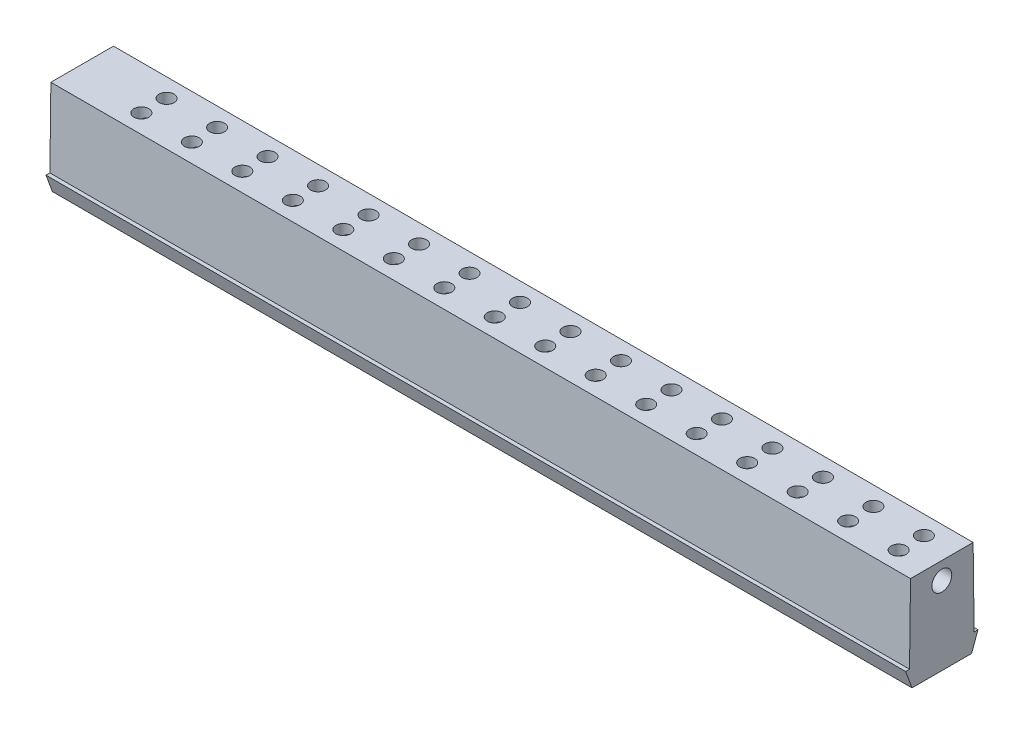
from build123d import *

# Parameters (mm, degrees)
BOSS_EXTRUDE1_DEPTH = 86.5
SKETCH2_R           = 1
CUT_EXTRUDE1_DEPTH  = 84
SKETCH3_R           = 0.9144
CUT_EXTRUDE2_DEPTH  = 5.207
SKETCH4_R           = 0.75
CUT_EXTRUDE3_DEPTH  = 5.08
LPATTERN1_COUNT     = 16
LPATTERN1_PITCH     = 5.08


with BuildPart() as part:
    # Sketch1 → Boss-Extrude1 (new body)
    with BuildSketch(Plane(origin=(0, 0, 0), x_dir=(0, 0, -1), z_dir=(1, 0, 0))):
        Polygon((-3, 0), (3, 0), (3.64, 1.75), (3.25, 1.75), (3.15, 9.6), (-3.15, 9.6), (-3.25, 1.75), (-3.64, 1.75), align=None)
    extrude(amount=BOSS_EXTRUDE1_DEPTH)

    # Sketch2 → Cut-Extrude1 (cut)
    with BuildSketch(Plane.ZY.offset(-86.5)):
        with Locations((0, 7.85)):
            Circle(SKETCH2_R)
    extrude(amount=CUT_EXTRUDE1_DEPTH, mode=Mode.SUBTRACT)

    # Sketch3 → Cut-Extrude2 (cut)
    with BuildSketch(Plane.XZ):
        with Locations((83.425, 1.27)):
            Circle(SKETCH3_R)
        with Locations((78.345, -1.27)):
            Circle(SKETCH3_R)
        with Locations((73.265, 1.27)):
            Circle(SKETCH3_R)
        with Locations((68.185, -1.27)):
            Circle(SKETCH3_R)
        with Locations((58.025, -1.27)):
            Circle(SKETCH3_R)
        with Locations((52.945, 1.27)):
            Circle(SKETCH3_R)
        with Locations((47.865, -1.27)):
            Circle(SKETCH3_R)
        with Locations((37.705, -1.27)):
            Circle(SKETCH3_R)
        with Locations((32.625, 1.27)):
            Circle(SKETCH3_R)
        with Locations((27.545, -1.27)):
            Circle(SKETCH3_R)
        with Locations((22.465, 1.27)):
            Circle(SKETCH3_R)
        with Locations((17.385, -1.27)):
            Circle(SKETCH3_R)
        with Locations((12.305, 1.27)):
            Circle(SKETCH3_R)
        with Locations((7.225, -1.27)):
            Circle(SKETCH3_R)
        with Locations((63.105, 1.27)):
            Circle(SKETCH3_R)
        with Locations((42.785, 1.27)):
            Circle(SKETCH3_R)
    extrude(amount=-CUT_EXTRUDE2_DEPTH, mode=Mode.SUBTRACT)

    # Sketch4 → Cut-Extrude3 (cut)
    with BuildSketch(Plane(origin=(0, 9.6, 0), x_dir=(1, 0, 0), z_dir=(0, 1, 0))):
        with Locations((7.225, 1.27)):
            Circle(SKETCH4_R)
        with Locations((7.225, -1.27)):
            Circle(SKETCH4_R)
    cut_extrude3 = extrude(amount=-CUT_EXTRUDE3_DEPTH, mode=Mode.SUBTRACT)

    # LPattern1: Cut-Extrude3 ×16
    with Locations(*[(i * LPATTERN1_PITCH, 0, 0) for i in range(1, LPATTERN1_COUNT)]):
        add(cut_extrude3, mode=Mode.SUBTRACT)


solid = part.part
